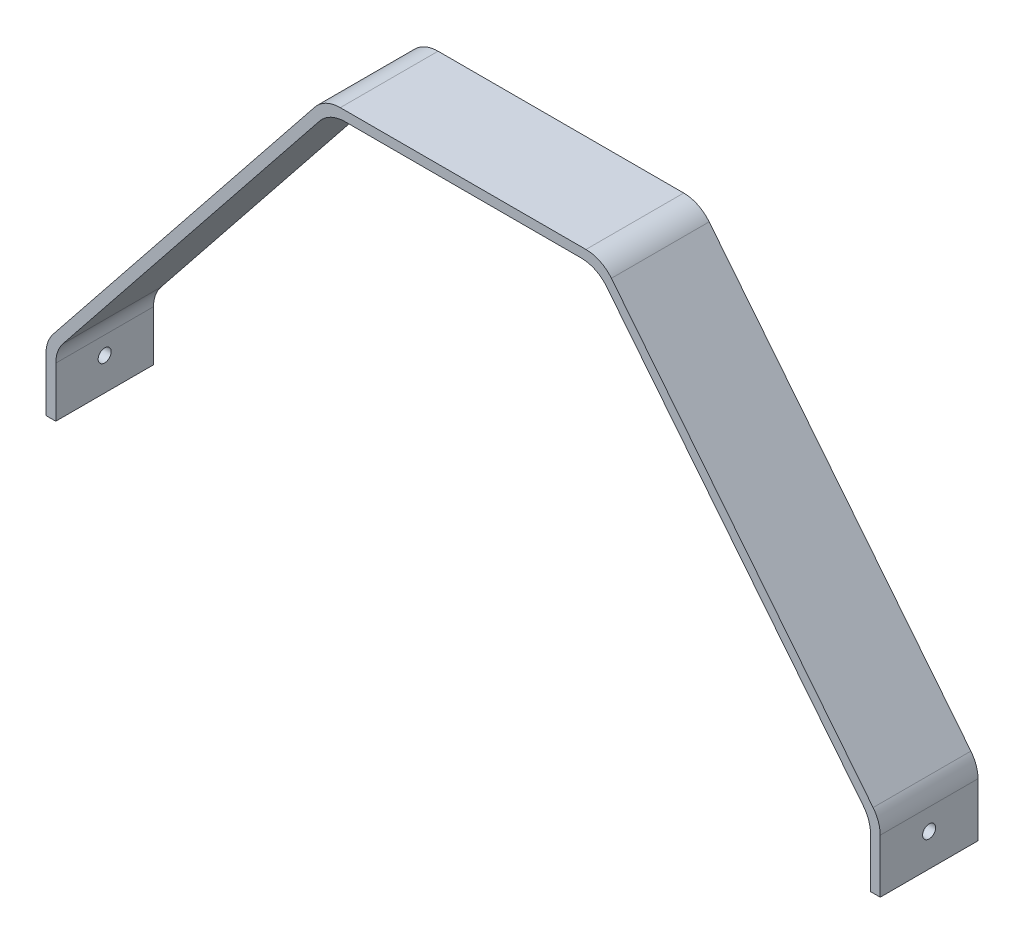
from build123d import *

# Parameters (mm, degrees)
BOSS_EXTRUDE1_DEPTH     = 30
FILLET1_R               = 10
SKETCH2_R               = 2
CUT_EXTRUDE1_DEPTH      = 1
CUT_EXTRUDE1_DEPTH_BACK = 257


with BuildPart() as part:
    # Sketch1 → Boss-Extrude1 (new body)
    with BuildSketch(Plane.XY):
        Polygon((128, -127), (125, -127), (125, -108.051382857), (41.057072577, -3), (-41.057072577, -3), (-125, -108.051382857), (-125, -127), (-128, -127), (-128, -107), (-42.5, 0), (42.5, 0), (128, -107), align=None)
    extrude(amount=BOSS_EXTRUDE1_DEPTH)

    # Fillet1
    fillet1_edges = [part.edges().sort_by_distance(p)[0] for p in [
        (125, -108.051382857, 15),
        (41.057072577, -3, 15),
        (-41.057072577, -3, 15),
        (-125, -108.051382857, 15),
        (-128, -107, 15),
        (-42.5, 0, 15),
        (42.5, 0, 15),
        (128, -107, 15),
    ]]
    fillet(fillet1_edges, radius=FILLET1_R)

    # Sketch2 → Cut-Extrude1 (cut, two sides)
    with BuildSketch(Plane(origin=(128, 0, 0), x_dir=(0, 0, -1), z_dir=(1, 0, 0))) as cut_extrude1_sk:
        with Locations((-15, -117)):
            Circle(SKETCH2_R)
    extrude(amount=CUT_EXTRUDE1_DEPTH, mode=Mode.SUBTRACT)
    extrude(cut_extrude1_sk.sketch, amount=-CUT_EXTRUDE1_DEPTH_BACK, mode=Mode.SUBTRACT)


solid = part.part
